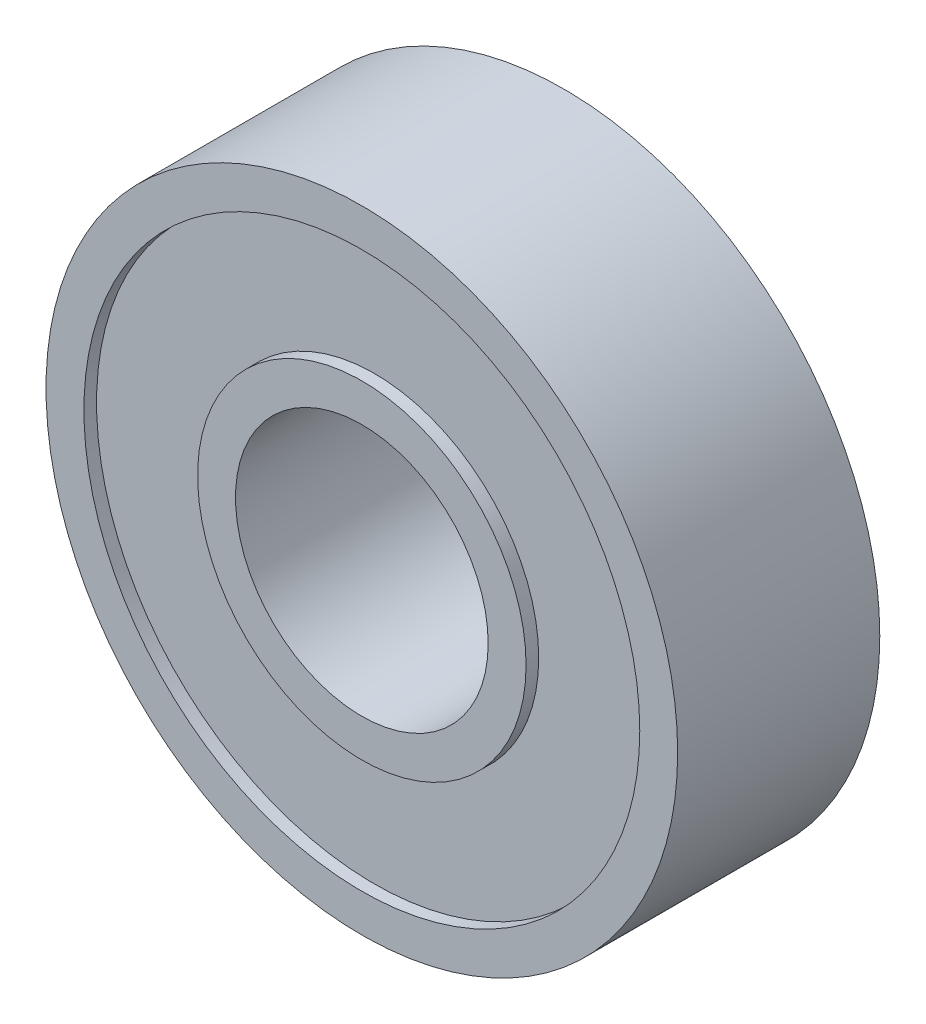
from build123d import *

# Parameters (mm, degrees)
SALIENTE_EXTRUIR1_DEPTH        = 4
SALIENTE_EXTRUIR1_DEPTH_BACK   = 4
CROQUIS1_R                     = 12.5
CROQUIS1_R_2                   = 11
SALIENTE_EXTRUIR1_2_DEPTH      = 4
SALIENTE_EXTRUIR1_2_DEPTH_BACK = 4
CROQUIS1_R_3                   = 6.5
CROQUIS1_R_4                   = 5
SALIENTE_EXTRUIR2_DEPTH        = 3.5
SALIENTE_EXTRUIR2_DEPTH_BACK   = 3.5
CROQUIS1_4_R                   = 11
CROQUIS1_4_R_2                 = 6.5


with BuildPart() as part:
    # Croquis1 → Saliente-Extruir1 (new, two sides: drawn at the far end of the back side and taken through both)
    with BuildSketch(Plane.XY.offset(-SALIENTE_EXTRUIR1_DEPTH_BACK)):
        Circle(CROQUIS1_R)
        Circle(CROQUIS1_R_2, mode=Mode.SUBTRACT)
    extrude(amount=SALIENTE_EXTRUIR1_DEPTH + SALIENTE_EXTRUIR1_DEPTH_BACK)



with BuildPart() as body_2:
    # Croquis1 → Saliente-Extruir1 2 (new, two sides: drawn at the far end of the back side and taken through both)
    with BuildSketch(Plane.XY.offset(-SALIENTE_EXTRUIR1_2_DEPTH_BACK)):
        Circle(CROQUIS1_R_3)
        Circle(CROQUIS1_R_4, mode=Mode.SUBTRACT)
    extrude(amount=SALIENTE_EXTRUIR1_2_DEPTH + SALIENTE_EXTRUIR1_2_DEPTH_BACK)


with BuildPart() as part_1:
    add(part.part)

    add(body_2.part)  # Saliente-Extruir2 merges body 2
    # Croquis1_4 → Saliente-Extruir2 (add, two sides: drawn at the far end of the back side and taken through both)
    with BuildSketch(Plane.XY.offset(-SALIENTE_EXTRUIR2_DEPTH_BACK)):
        Circle(CROQUIS1_4_R)
        Circle(CROQUIS1_4_R_2, mode=Mode.SUBTRACT)
    extrude(amount=SALIENTE_EXTRUIR2_DEPTH + SALIENTE_EXTRUIR2_DEPTH_BACK)


solid = part_1.part
